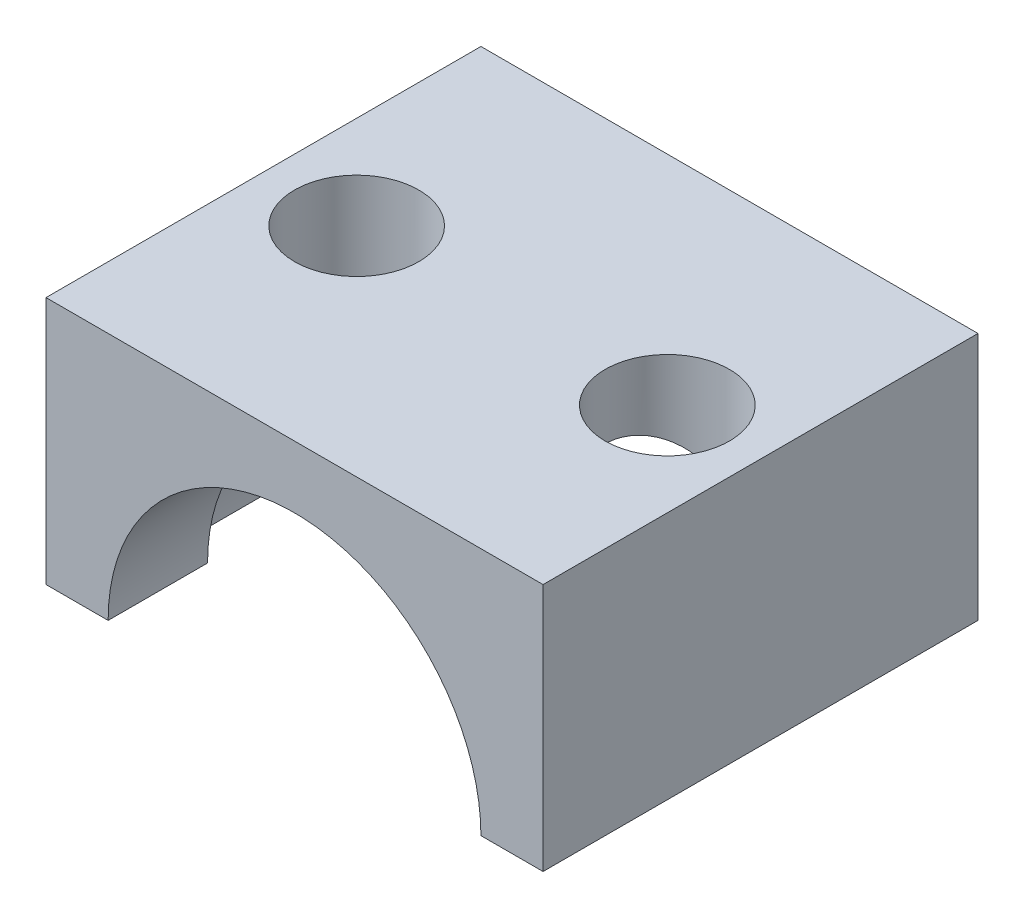
from build123d import *

# Parameters (mm, degrees)
EXTRUSION1_DEPTH      = 14
ESQUISSE3_R           = 7
EXTRUSION2_DEPTH      = 3.8
EXTRUSION2_DEPTH_BACK = 3.8
ESQUISSE4_R           = 2
EXTRUSION3_DEPTH      = 9


with BuildPart() as part:
    # Esquisse1 → Extrusion1 (new body)
    with BuildSketch(Plane.XY):
        with BuildLine():
            Line((8, 0), (6, 0))
            ThreePointArc((6, 0), (0, 6), (-6, 0))
            Line((-6, 0), (-8, 0))
            Line((-8, 0), (-8, 8))
            Line((-8, 8), (8, 8))
            Line((8, 8), (8, 0))
        make_face()
    extrude(amount=EXTRUSION1_DEPTH)

    # Esquisse3 → Extrusion2 (cut, two sides)
    with BuildSketch(Plane.XY.offset(7)) as extrusion2_sk:
        with Locations((0, -0.399862153)):
            Circle(ESQUISSE3_R)
    extrude(amount=EXTRUSION2_DEPTH, mode=Mode.SUBTRACT)
    extrude(extrusion2_sk.sketch, amount=-EXTRUSION2_DEPTH_BACK, mode=Mode.SUBTRACT)

    # Esquisse4 → Extrusion3 (cut, through all)
    with BuildSketch(Plane(origin=(0, 8, 0), x_dir=(1, 0, 0), z_dir=(0, 1, 0))):
        with Locations((-5, -7)):
            Circle(ESQUISSE4_R)
        with Locations((5, -7)):
            Circle(ESQUISSE4_R)
    extrude(amount=-EXTRUSION3_DEPTH, mode=Mode.SUBTRACT)


solid = part.part
